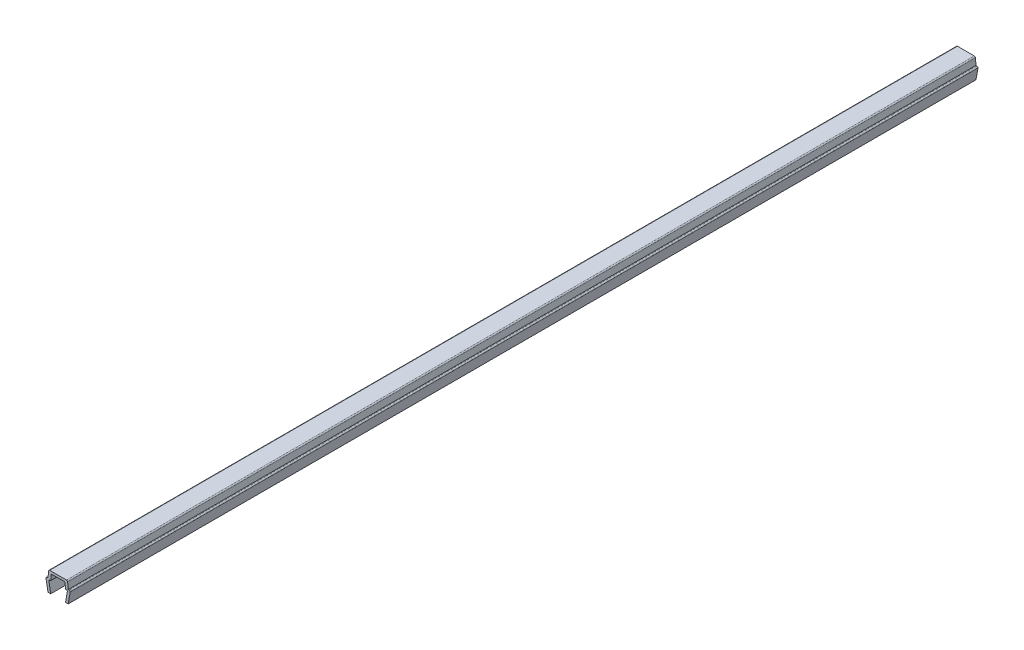
from build123d import *

# Parameters (mm, degrees)
BOSS_EXTRUDE1_DEPTH = 135


with BuildPart() as part:
    # Sketch1 → Boss-Extrude1 (new body, symmetric)
    with BuildSketch(Plane.XY):
        with BuildLine():
            Line((-3.6, 3.35), (-3, 0))
            Line((-3, 0), (-2.2, 0))
            Line((-2.2, 0), (-2.735217071, 2.988295315))
            ThreePointArc((-2.735217071, 2.988295315), (-2.659117427, 3.274614514), (-2.390699246, 3.4))
            Line((-2.390699246, 3.4), (-2.2, 3.4))
            Line((-2.2, 3.4), (-2.070472639, 4.88050451))
            ThreePointArc((-2.070472639, 4.88050451), (-1.958261067, 5.108047068), (-1.721804495, 5.2))
            Line((-1.721804495, 5.2), (1.721804495, 5.2))
            ThreePointArc((1.721804495, 5.2), (1.958261067, 5.108047068), (2.070472639, 4.88050451))
            Line((2.070472639, 4.88050451), (2.2, 3.4))
            Line((2.2, 3.4), (2.390699246, 3.4))
            ThreePointArc((2.390699246, 3.4), (2.659117427, 3.274614514), (2.735217071, 2.988295315))
            Line((2.735217071, 2.988295315), (2.2, 0))
            Line((2.2, 0), (3, 0))
            Line((3, 0), (3.6, 3.35))
            ThreePointArc((3.6, 3.35), (3.497487373, 3.597487373), (3.25, 3.7))
            Line((3.25, 3.7), (3, 3.7))
            Line((3, 3.7), (2.835477174, 5.58050451))
            ThreePointArc((2.835477174, 5.58050451), (2.723265602, 5.808047068), (2.486809029, 5.9))
            Line((2.486809029, 5.9), (-2.486809029, 5.9))
            ThreePointArc((-2.486809029, 5.9), (-2.723265602, 5.808047068), (-2.835477174, 5.58050451))
            Line((-2.835477174, 5.58050451), (-3, 3.7))
            Line((-3, 3.7), (-3.25, 3.7))
            ThreePointArc((-3.25, 3.7), (-3.497487373, 3.597487373), (-3.6, 3.35))
        make_face()
    extrude(amount=BOSS_EXTRUDE1_DEPTH, both=True)


solid = part.part
